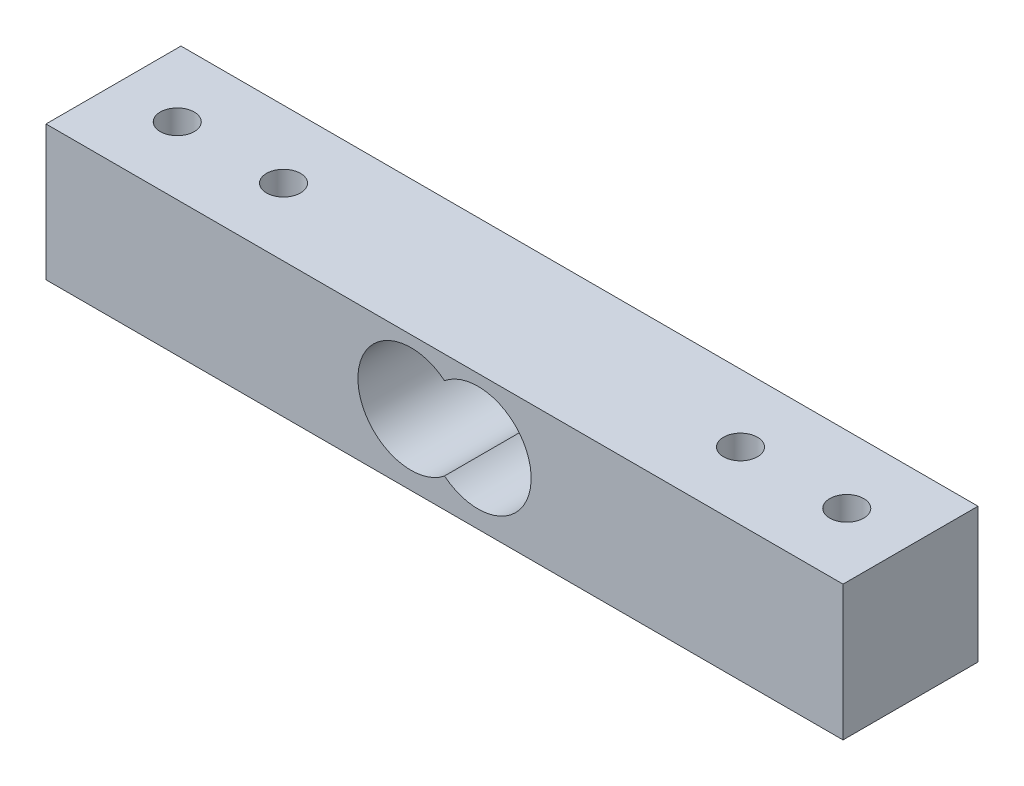
from build123d import *

# Parameters (mm, degrees)
SKETCH2_W           = 75
SKETCH2_H           = 12.7
BOSS_EXTRUDE1_DEPTH = 12.7
CUT_EXTRUDE1_DEPTH  = 12.7
SKETCH4_R           = 1.6
CUT_EXTRUDE2_DEPTH  = 13.7


with BuildPart() as part:
    # Sketch2 → Boss-Extrude1 (new body)
    with BuildSketch(Plane(origin=(0, 0, 0), x_dir=(1, 0, 0), z_dir=(0, 1, 0))):
        with Locations((11.2745, 0.22225)):
            Rectangle(SKETCH2_W, SKETCH2_H)
    extrude(amount=BOSS_EXTRUDE1_DEPTH)

    # Sketch3 → Cut-Extrude1 (cut)
    with BuildSketch(Plane.XY.offset(6.12775)):
        with BuildLine():
            ThreePointArc((11.2745, 10.531229249), (3.1245, 6.648253585), (11.2745, 2.765277922))
            ThreePointArc((11.2745, 2.765277922), (19.4245, 6.648253585), (11.2745, 10.531229249))
        make_face()
    extrude(amount=-CUT_EXTRUDE1_DEPTH, mode=Mode.SUBTRACT)

    # Sketch4 → Cut-Extrude2 (cut, through all)
    with BuildSketch(Plane(origin=(0, 12.7, 0), x_dir=(1, 0, 0), z_dir=(0, 1, 0))):
        with Locations((-20.2255, 0.22225)):
            Circle(SKETCH4_R)
        with Locations((-10.2255, 0.22225)):
            Circle(SKETCH4_R)
        with Locations((32.7745, 0.22225)):
            Circle(SKETCH4_R)
        with Locations((42.7745, 0.22225)):
            Circle(SKETCH4_R)
    extrude(amount=-CUT_EXTRUDE2_DEPTH, mode=Mode.SUBTRACT)


solid = part.part
